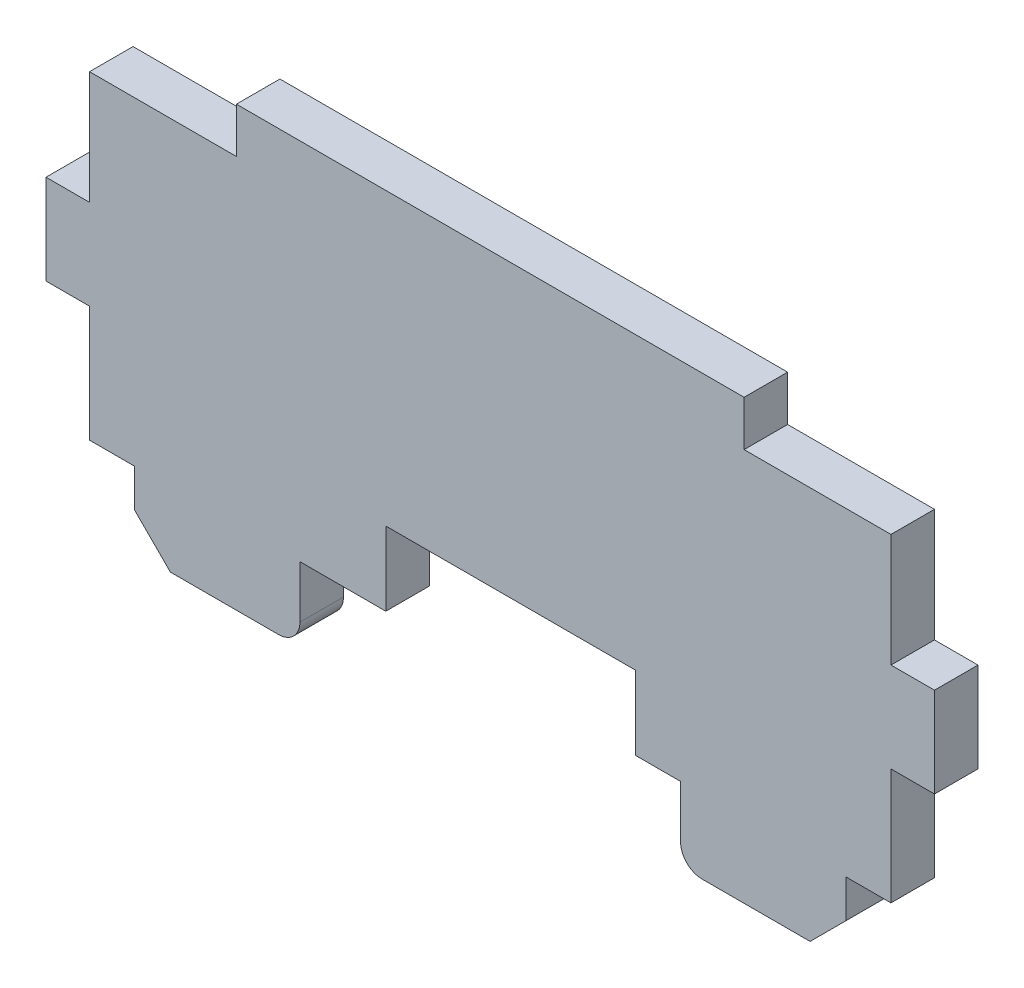
from build123d import *

# Parameters (mm, degrees)
BOSS_EXTRUDE1_DEPTH = 3.048


with BuildPart() as part:
    # Model → Boss-Extrude1 (new body)
    with BuildSketch(Plane.XY):
        with BuildLine():
            Line((59.181999415, 5.17), (59.181999415, 13.297999725))
            Line((59.181999415, 13.297999725), (62.229999341, 13.297999725))
            Line((62.229999341, 13.297999725), (62.229999341, 19.597199261))
            Line((62.229999341, 19.597199261), (59.181999415, 19.597199261))
            Line((59.181999415, 19.597199261), (59.181999415, 27.522))
            Line((59.181999415, 27.522), (48.894999549, 27.522))
            Line((48.894999549, 27.522), (48.894999549, 30.696999729))
            Line((48.894999549, 30.696999729), (13.335000724, 30.696999729))
            Line((13.335000724, 30.696999729), (13.335000724, 27.522))
            Line((13.335000724, 27.522), (3.047998995, 27.522))
            Line((3.047998995, 27.522), (3.047998995, 19.597199261))
            Line((3.047998995, 19.597199261), (0, 19.597199261))
            Line((0, 19.597199261), (0, 13.297999725))
            Line((0, 13.297999725), (3.047998995, 13.297999725))
            Line((3.047998995, 13.297999725), (3.047998995, 5.17))
            Line((3.047998995, 5.17), (6.21299938, 5.17))
            Line((6.21299938, 5.17), (6.21299938, 2.5))
            Line((6.21299938, 2.5), (8.71299938, 0))
            Line((8.71299938, 0), (16.28499938, 0))
            ThreePointArc((16.28499938, 0), (17.345659551, 0.439339828), (17.78499938, 1.5))
            Line((17.78499938, 1.5), (17.78499938, 5.17))
            Line((17.78499938, 5.17), (23.799799458, 5.17))
            Line((23.799799458, 5.17), (23.799799458, 10.34))
            Line((23.799799458, 10.34), (41.274999458, 10.34))
            Line((41.274999458, 10.34), (41.274999458, 5.17))
            Line((41.274999458, 5.17), (44.444999458, 5.17))
            Line((44.444999458, 5.17), (44.444999458, 1.5))
            ThreePointArc((44.444999458, 1.5), (44.884339286, 0.439339828), (45.944999458, 0))
            Line((45.944999458, 0), (53.516999458, 0))
            Line((53.516999458, 0), (56.016999458, 2.5))
            Line((56.016999458, 2.5), (56.016999458, 5.17))
            Line((56.016999458, 5.17), (59.181999415, 5.17))
        make_face()
    extrude(amount=BOSS_EXTRUDE1_DEPTH)


solid = part.part
